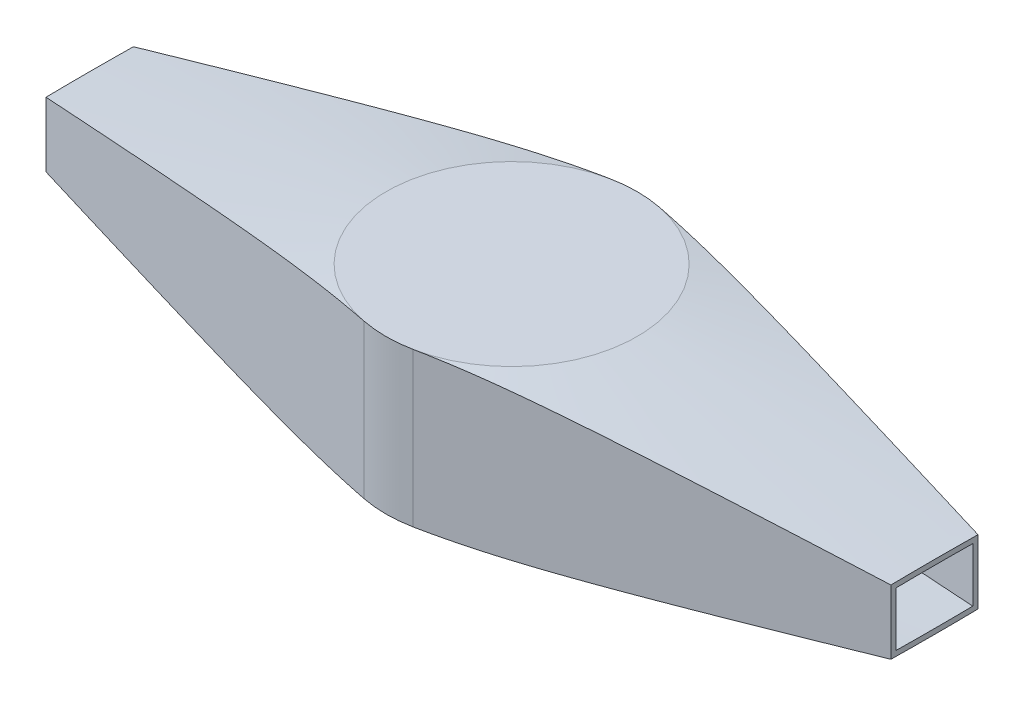
from build123d import *

# Parameters (mm, degrees)
SKETCH_1_R               = 49
EXTRUDE_1_DEPTH          = 30
SKETCH_16_R              = 250
SKETCH_16_5_R            = 250
SKETCH_14_OUTSIDE_W      = 643.93
SKETCH_14_OUTSIDE_H      = 643.93
CUT_EXTRUDE_1_DEPTH      = 355.823900134
CUT_EXTRUDE_1_DEPTH_BACK = 355.823900134
SHELL_1_T                = 2
SKETCH_15_OUTSIDE_W      = 604.606
SKETCH_15_OUTSIDE_H      = 202.606
CUT_EXTRUDE_2_DEPTH      = 257.517055963
CUT_EXTRUDE_2_DEPTH_BACK = 257.517055963


with BuildPart() as part:
    # 草图1 → 凸台-拉伸1 (new, symmetric)
    with BuildSketch(Plane(origin=(0, 0, 0), x_dir=(1, 0, 0), z_dir=(0, 1, 0))):
        with Locations(Location((0, 0, 0), (0, 0, 270))):
            Circle(SKETCH_1_R)
    extrude(amount=EXTRUDE_1_DEPTH, both=True)

    # 草图16 → section 0 of loft_1
    with BuildSketch(Plane(origin=(0, 0, 0), x_dir=(1, 0, 0), z_dir=(0, 1, 0)), mode=Mode.PRIVATE) as loft_1_s0:
        Circle(SKETCH_16_R)
    # loft up to a face of the part (loft_1)
    loft([loft_1_s0.sketch, Face(Wire([part.edges().sort_by_distance((35.719462744, 30, -33.542808191))[0]]))])

    # 草图16<5> → section 0 of loft_3
    with BuildSketch(Plane(origin=(0, 0, 0), x_dir=(1, 0, 0), z_dir=(0, 1, 0)), mode=Mode.PRIVATE) as loft_3_s0:
        Circle(SKETCH_16_5_R)
    # loft up to a face of the part (loft_3)
    loft([loft_3_s0.sketch, Face(Wire([part.edges().sort_by_distance((-35.719462744, -30, -33.542808191))[0]]))])

    # 草图14 outside → 切除-拉伸1 (cut, two sides)
    with BuildSketch(Plane(origin=(0, 0, 0), x_dir=(1, 0, 0), z_dir=(0, 1, 0))) as cut_extrude_1_sk:
        Rectangle(SKETCH_14_OUTSIDE_W, SKETCH_14_OUTSIDE_H)
        with BuildLine():
            Line((-250, 0), (-9.604, -48.049590883))
            ThreePointArc((-9.604, -48.049590883), (0, -49), (9.604, -48.049590883))
            Line((9.604, -48.049590883), (250, 0))
            Line((250, 0), (9.604, 48.049590883))
            ThreePointArc((9.604, 48.049590883), (1.6e-08, 49), (-9.603999968, 48.049590889))
            Line((-9.603999968, 48.049590889), (-250, 0))
        make_face(mode=Mode.SUBTRACT)
    extrude(amount=CUT_EXTRUDE_1_DEPTH, mode=Mode.SUBTRACT)
    extrude(cut_extrude_1_sk.sketch, amount=-CUT_EXTRUDE_1_DEPTH_BACK, mode=Mode.SUBTRACT)

    # 抽壳1 (no face opened: a closed hollow body)
    add(offset(amount=-SHELL_1_T, mode=Mode.PRIVATE), mode=Mode.SUBTRACT)

    # 草图15 outside → 切除-拉伸2 (cut, two sides)
    with BuildSketch(Plane(origin=(0, 0, 0), x_dir=(1, 0, 0), z_dir=(0, 1, 0))) as cut_extrude_2_sk:
        Rectangle(SKETCH_15_OUTSIDE_W, SKETCH_15_OUTSIDE_H)
        with BuildLine():
            Line((-9.60400022, -48.049590839), (-164.621347882, -17.065214498))
            Line((-164.621347882, -17.065214498), (-164.621347882, 17.065214498))
            Line((-164.621347882, 17.065214498), (-9.604, 48.049590883))
            ThreePointArc((-9.604, 48.049590883), (0, 49), (9.604, 48.049590883))
            Line((9.604, 48.049590883), (165, 16.989530712))
            Line((165, 16.989530712), (165, -16.989530712))
            Line((165, -16.989530712), (9.604, -48.049590883))
            ThreePointArc((9.604, -48.049590883), (-1.12e-07, -49), (-9.60400022, -48.049590839))
        make_face(mode=Mode.SUBTRACT)
    extrude(amount=CUT_EXTRUDE_2_DEPTH, mode=Mode.SUBTRACT)
    extrude(cut_extrude_2_sk.sketch, amount=-CUT_EXTRUDE_2_DEPTH_BACK, mode=Mode.SUBTRACT)


solid = part.part
